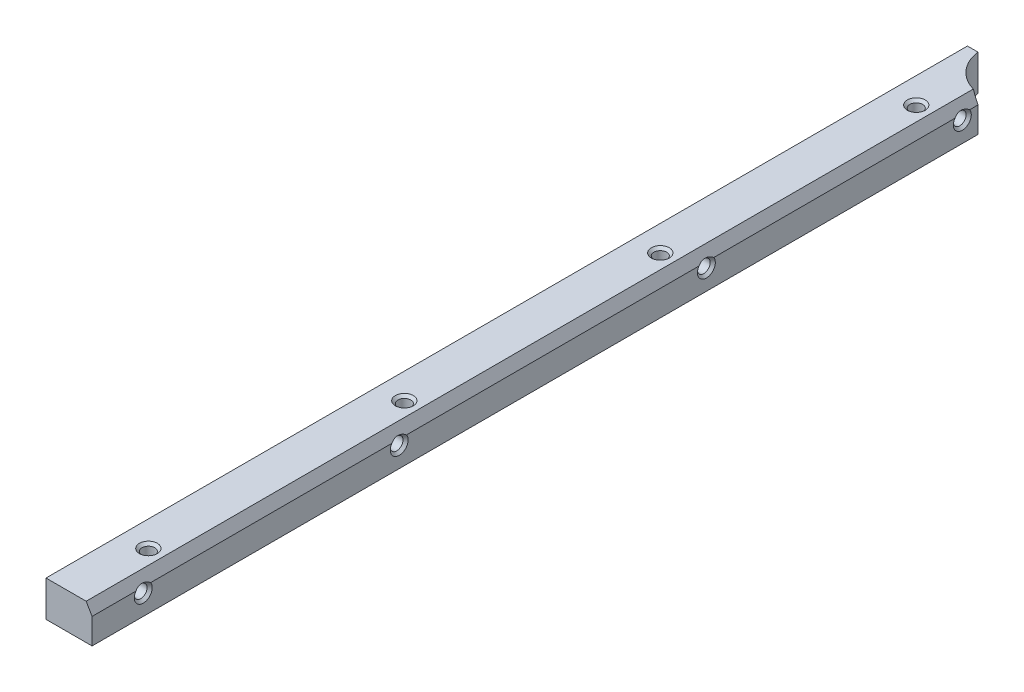
from build123d import *

# Parameters (mm, degrees)
SKETCH_1_W                 = 9
SKETCH_1_H                 = 7
EXTRUDE_1_DEPTH            = 180
CUT_EXTRUDE_1_DEPTH        = 1
CUT_EXTRUDE_1_DEPTH_BACK   = 8
CHAMFER_1_SIZE             = 2
CHAMFER_1_SIZE2            = 1.154700538
HOLE_WIZARD_M31_AT_2_COUNT = 2
HOLE_WIZARD_M31_AT_2_PITCH = 50
HOLE_WIZARD_M31_AT_3_COUNT = 2
HOLE_WIZARD_M31_AT_3_PITCH = 100
HOLE_WIZARD_M31_AT_4_COUNT = 2
HOLE_WIZARD_M31_AT_4_PITCH = 150
HOLE_WIZARD_M32_AT_2_COUNT = 2
HOLE_WIZARD_M32_AT_2_PITCH = 50
HOLE_WIZARD_M32_AT_3_COUNT = 2
HOLE_WIZARD_M32_AT_3_PITCH = 110
HOLE_WIZARD_M32_AT_4_COUNT = 2
HOLE_WIZARD_M32_AT_4_PITCH = 160


with BuildPart() as part:
    # Эскиз1 → Бобышка-Вытянуть1 (new body)
    with BuildSketch(Plane.XY):
        with Locations((4.5, 3.5)):
            Rectangle(SKETCH_1_W, SKETCH_1_H)
    extrude(amount=EXTRUDE_1_DEPTH)

    # Эскиз6 → Вырез-Вытянуть1 (cut, two sides)
    with BuildSketch(Plane.XZ) as cut_extrude_1_sk:
        with BuildLine():
            Line((-44.220662013, -367.363162821), (2.062746067, 0))
            ThreePointArc((2.062746067, 0), (4.343145751, 4.656854249), (9, 6.937253933))
            Line((9, 6.937253933), (376.363162821, 53.220662013))
            Line((376.363162821, 53.220662013), (900.000150172, -470.416325339))
            Line((900.000150172, -470.416325339), (479.416325339, -891.000150172))
            Line((479.416325339, -891.000150172), (-44.220662013, -367.363162821))
        make_face()
    extrude(amount=CUT_EXTRUDE_1_DEPTH, mode=Mode.SUBTRACT)
    extrude(cut_extrude_1_sk.sketch, amount=-CUT_EXTRUDE_1_DEPTH_BACK, mode=Mode.SUBTRACT)

    # Фаска1
    chamfer_1_edges = [part.edges().sort_by_distance(p)[0] for p in [
        (9, 7, 93.468626967),
    ]]
    chamfer_1_side = [part.faces().sort_by_distance(p)[0] for p in [
        (9, 3.5, 93.468626967),
    ]]
    chamfer(chamfer_1_edges, length=CHAMFER_1_SIZE, length2=CHAMFER_1_SIZE2, reference=chamfer_1_side[0])

    # Эскиз2 → Отверстие обработанное метчиком M31 (revolve, cut)
    with BuildSketch(Plane(origin=(5, 0, 15), x_dir=(0, 0, -1), z_dir=(1, 0, 0))):
        Polygon((0, 0), (0, 7), (1.75, 7), (1.25, 6.5), (1.25, 0.5), (1.75, 0), align=None)
    hole_wizard_m31 = revolve(axis=Axis((5, -6.35, 15), (0, 1, 0)), mode=Mode.SUBTRACT)

    # Отверстие обработанное метчиком M31 at 2: Отверстие обработанное метчиком M31 ×2
    with Locations(*[(0, 0, i * HOLE_WIZARD_M31_AT_2_PITCH) for i in range(1, HOLE_WIZARD_M31_AT_2_COUNT)]):
        add(hole_wizard_m31, mode=Mode.SUBTRACT)

    # Отверстие обработанное метчиком M31 at 3: Отверстие обработанное метчиком M31 ×2
    with Locations(*[(0, 0, i * HOLE_WIZARD_M31_AT_3_PITCH) for i in range(1, HOLE_WIZARD_M31_AT_3_COUNT)]):
        add(hole_wizard_m31, mode=Mode.SUBTRACT)

    # Отверстие обработанное метчиком M31 at 4: Отверстие обработанное метчиком M31 ×2
    with Locations(*[(0, 0, i * HOLE_WIZARD_M31_AT_4_PITCH) for i in range(1, HOLE_WIZARD_M31_AT_4_COUNT)]):
        add(hole_wizard_m31, mode=Mode.SUBTRACT)

    # Эскиз4 → Отверстие обработанное метчиком M32 (revolve, cut)
    with BuildSketch(Plane(origin=(0, 4, 10), x_dir=(0, 0, 1), z_dir=(0, 1, 0))):
        Polygon((0, 0), (0, 9), (1.75, 9), (1.25, 8.5), (1.25, 0.5), (1.75, 0), align=None)
    hole_wizard_m32 = revolve(axis=Axis((-6.35, 4, 10), (1, 0, 0)), mode=Mode.SUBTRACT)

    # Отверстие обработанное метчиком M32 at 2: Отверстие обработанное метчиком M32 ×2
    with Locations(*[(0, 0, i * HOLE_WIZARD_M32_AT_2_PITCH) for i in range(1, HOLE_WIZARD_M32_AT_2_COUNT)]):
        add(hole_wizard_m32, mode=Mode.SUBTRACT)

    # Отверстие обработанное метчиком M32 at 3: Отверстие обработанное метчиком M32 ×2
    with Locations(*[(0, 0, i * HOLE_WIZARD_M32_AT_3_PITCH) for i in range(1, HOLE_WIZARD_M32_AT_3_COUNT)]):
        add(hole_wizard_m32, mode=Mode.SUBTRACT)

    # Отверстие обработанное метчиком M32 at 4: Отверстие обработанное метчиком M32 ×2
    with Locations(*[(0, 0, i * HOLE_WIZARD_M32_AT_4_PITCH) for i in range(1, HOLE_WIZARD_M32_AT_4_COUNT)]):
        add(hole_wizard_m32, mode=Mode.SUBTRACT)


solid = part.part
